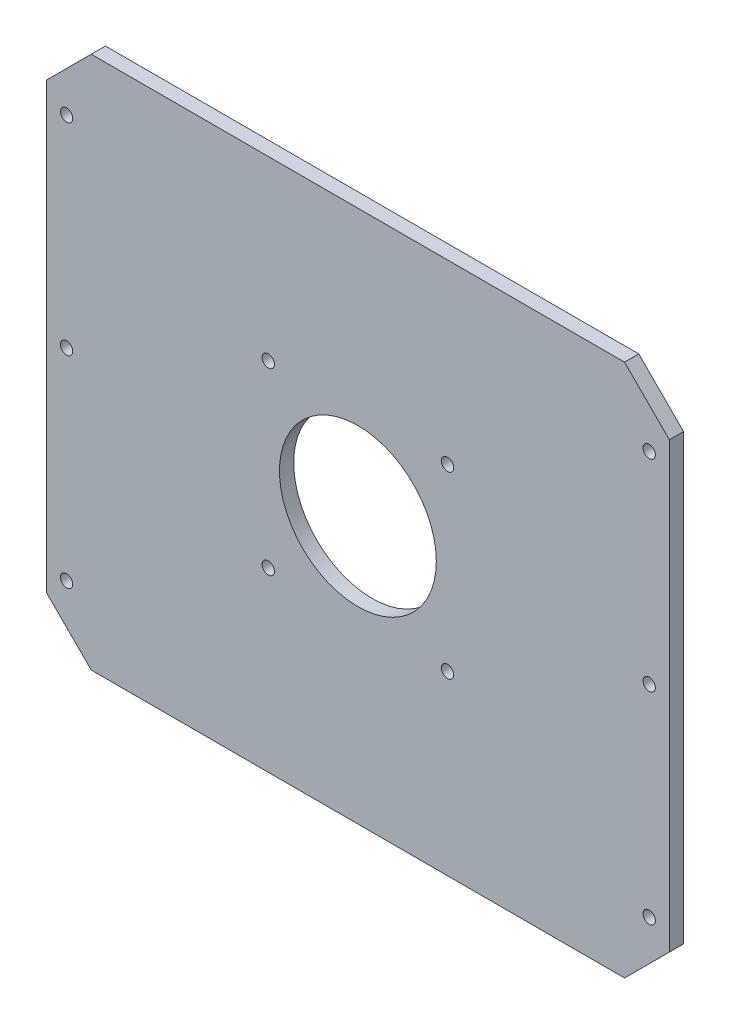
from build123d import *

# Parameters (mm, degrees)
SKETCH1_W           = 278
SKETCH1_H           = 238
BOSS_EXTRUDE1_DEPTH = 6.35
SKETCH2_R           = 35
SKETCH2_R_2         = 2.75
CUT_EXTRUDE1_DEPTH  = 7.35
CHAMFER1_SIZE       = 20
SKETCH4_R           = 2.75
CUT_EXTRUDE2_DEPTH  = 76.2


with BuildPart() as part:
    # Sketch1 → Boss-Extrude1 (new body)
    with BuildSketch(Plane.XY):
        Rectangle(SKETCH1_W, SKETCH1_H)
    extrude(amount=BOSS_EXTRUDE1_DEPTH)

    # Sketch2 → Cut-Extrude1 (cut, through all)
    with BuildSketch(Plane.XY.offset(6.35)):
        Circle(SKETCH2_R)
        with Locations((-40, 40)):
            Circle(SKETCH2_R_2)
        with Locations((40, 40)):
            Circle(SKETCH2_R_2)
        with Locations((40, -40)):
            Circle(SKETCH2_R_2)
        with Locations((-40, -40)):
            Circle(SKETCH2_R_2)
    extrude(amount=-CUT_EXTRUDE1_DEPTH, mode=Mode.SUBTRACT)

    # Chamfer1
    chamfer1_edges = [part.edges().sort_by_distance(p)[0] for p in [
        (-139, 119, 3.175),
        (139, 119, 3.175),
        (139, -119, 3.175),
        (-139, -119, 3.175),
    ]]
    chamfer(chamfer1_edges, length=CHAMFER1_SIZE)

    # Sketch4 → Cut-Extrude2 (cut)
    with BuildSketch(Plane.XY.offset(6.35)):
        with Locations((-130, 90)):
            Circle(SKETCH4_R)
        with Locations((130, 90)):
            Circle(SKETCH4_R)
        with Locations((-130, -90)):
            Circle(SKETCH4_R)
        with Locations((130, -90)):
            Circle(SKETCH4_R)
        with Locations((-130, 0)):
            Circle(SKETCH4_R)
        with Locations((130, 0)):
            Circle(SKETCH4_R)
    extrude(amount=-CUT_EXTRUDE2_DEPTH, mode=Mode.SUBTRACT)


solid = part.part
